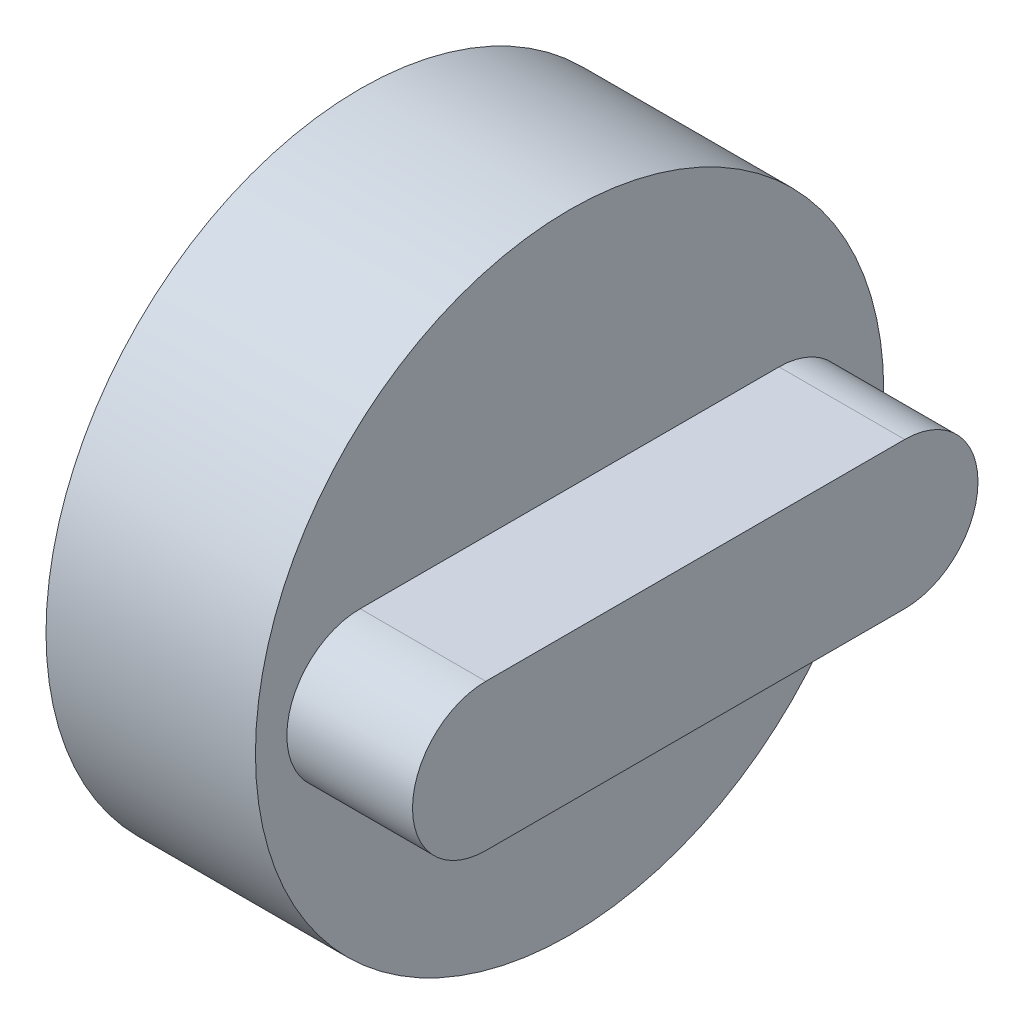
from build123d import *

# Parameters (mm, degrees)
SKETCH2_R           = 15
BOSS_EXTRUDE1_DEPTH = 10
BOSS_EXTRUDE2_DEPTH = 6
SKETCH4_R           = 2.5
CUT_EXTRUDE1_DEPTH  = 8
SKETCH6_W           = 0.825946649
SKETCH6_H           = 5.007301559
BOSS_EXTRUDE3_DEPTH = 15


with BuildPart() as part:
    # Sketch2 → Boss-Extrude1 (new body)
    with BuildSketch(Plane(origin=(0, 0, 0), x_dir=(0, 0, -1), z_dir=(1, 0, 0))):
        Circle(SKETCH2_R)
    extrude(amount=BOSS_EXTRUDE1_DEPTH)

    # Sketch3 → Boss-Extrude2 (add)
    with BuildSketch(Plane(origin=(10, 0, 0), x_dir=(0, 0, -1), z_dir=(1, 0, 0))):
        with BuildLine():
            Line((-10, 3.5), (10, 3.5))
            ThreePointArc((10, 3.5), (13.5, 0), (10, -3.5))
            Line((10, -3.5), (-10, -3.5))
            ThreePointArc((-10, -3.5), (-13.5, 0), (-10, 3.5))
        make_face()
    extrude(amount=BOSS_EXTRUDE2_DEPTH)

    # Sketch4 → Cut-Extrude1 (cut)
    with BuildSketch(Plane.ZY):
        Circle(SKETCH4_R)
    extrude(amount=-CUT_EXTRUDE1_DEPTH, mode=Mode.SUBTRACT)

    # Sketch6 → Boss-Extrude3 (add)
    with BuildSketch(Plane.ZY.offset(-8)):
        with Locations((-0.025810832, -0.051621665)):
            Rectangle(SKETCH6_W, SKETCH6_H)
    extrude(amount=BOSS_EXTRUDE3_DEPTH)


solid = part.part
